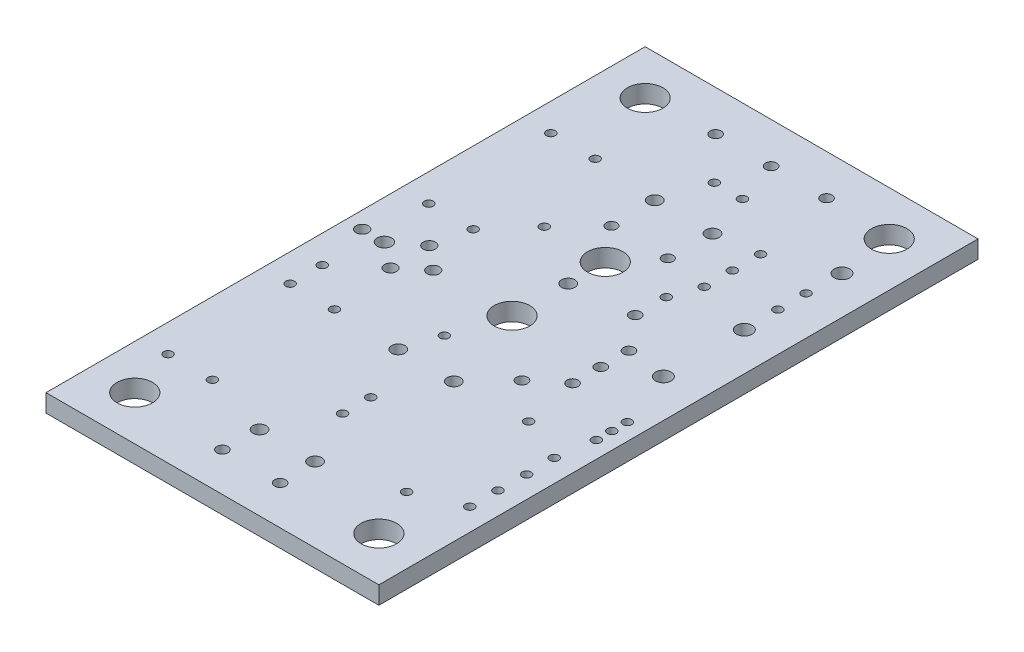
from build123d import *

# Parameters (mm, degrees)
ESQUISSE2_W      = 30
ESQUISSE2_H      = 54
ESQUISSE2_R      = 0.59944
ESQUISSE2_R_2    = 1.6002
ESQUISSE2_R_3    = 0.50038
ESQUISSE2_R_4    = 0.4826
ESQUISSE2_R_5    = 0.39878
ESQUISSE2_R_6    = 0.55118
ESQUISSE2_R_7    = 0.65024
ESQUISSE2_R_8    = 0.70104
ESQUISSE2_R_9    = 0.4
EXTRUSION1_DEPTH = 1.6


with BuildPart() as part:
    # Esquisse2 → Extrusion1 (new body)
    with BuildSketch(Plane(origin=(0, 0, 0), x_dir=(1, 0, 0), z_dir=(0, 1, 0))):
        with Locations((15, 27)):
            Rectangle(ESQUISSE2_W, ESQUISSE2_H)
        with Locations(Location((17.62252, 42.44594, 0), (0, 0, 270))):  # turned: the seam where the file's is
            Circle(ESQUISSE2_R, mode=Mode.SUBTRACT)
        with Locations(Location((12.4206, 42.44594, 0), (0, 0, 270))):  # turned: the seam where the file's is
            Circle(ESQUISSE2_R, mode=Mode.SUBTRACT)
        with Locations(Location((15.02156, 32.04464, 0), (0, 0, 270))):  # turned: the seam where the file's is
            Circle(ESQUISSE2_R, mode=Mode.SUBTRACT)
        with Locations(Location((15.00378, 35.40252, 0), (0, 0, 270))):  # turned: the seam where the file's is
            Circle(ESQUISSE2_R_2, mode=Mode.SUBTRACT)
        with Locations(Location((17.59966, 3.50012, 0), (0, 0, 270))):  # turned: the seam where the file's is
            Circle(ESQUISSE2_R_3, mode=Mode.SUBTRACT)
        with Locations(Location((12.40028, 3.50012, 0), (0, 0, 270))):  # turned: the seam where the file's is
            Circle(ESQUISSE2_R_3, mode=Mode.SUBTRACT)
        with Locations(Location((15.00124, 50.35042, 0), (0, 0, 270))):  # turned: the seam where the file's is
            Circle(ESQUISSE2_R_3, mode=Mode.SUBTRACT)
        with Locations(Location((19.99996, 50.35042, 0), (0, 0, 270))):  # turned: the seam where the file's is
            Circle(ESQUISSE2_R_3, mode=Mode.SUBTRACT)
        with Locations(Location((9.99998, 50.35042, 0), (0, 0, 270))):  # turned: the seam where the file's is
            Circle(ESQUISSE2_R_3, mode=Mode.SUBTRACT)
        with Locations(Location((12.49934, 19.25066, 0), (0, 0, 270))):  # turned: the seam where the file's is
            Circle(ESQUISSE2_R, mode=Mode.SUBTRACT)
        with Locations(Location((12.49934, 6.74878, 0), (0, 0, 270))):  # turned: the seam where the file's is
            Circle(ESQUISSE2_R, mode=Mode.SUBTRACT)
        with Locations(Location((17.5006, 19.25066, 0), (0, 0, 270))):  # turned: the seam where the file's is
            Circle(ESQUISSE2_R, mode=Mode.SUBTRACT)
        with Locations(Location((17.5006, 6.74878, 0), (0, 0, 270))):  # turned: the seam where the file's is
            Circle(ESQUISSE2_R, mode=Mode.SUBTRACT)
        with Locations(Location((20.50034, 22.40026, 0), (0, 0, 270))):  # turned: the seam where the file's is
            Circle(ESQUISSE2_R_3, mode=Mode.SUBTRACT)
        with Locations(Location((20.50034, 32.6009, 0), (0, 0, 270))):  # turned: the seam where the file's is
            Circle(ESQUISSE2_R_3, mode=Mode.SUBTRACT)
        with Locations(Location((12.46124, 38.49878, 0), (0, 0, 270))):  # turned: the seam where the file's is
            Circle(ESQUISSE2_R_4, mode=Mode.SUBTRACT)
        with Locations(Location((17.54124, 38.49878, 0), (0, 0, 270))):  # turned: the seam where the file's is
            Circle(ESQUISSE2_R_4, mode=Mode.SUBTRACT)
        with Locations(Location((16.27124, 46.49978, 0), (0, 0, 270))):  # turned: the seam where the file's is
            Circle(ESQUISSE2_R_5, mode=Mode.SUBTRACT)
        with Locations(Location((13.73124, 46.49978, 0), (0, 0, 270))):  # turned: the seam where the file's is
            Circle(ESQUISSE2_R_5, mode=Mode.SUBTRACT)
        with Locations(Location((15.00124, 11.72972, 0), (0, 0, 270))):  # turned: the seam where the file's is
            Circle(ESQUISSE2_R_5, mode=Mode.SUBTRACT)
        with Locations(Location((15.00124, 14.26972, 0), (0, 0, 270))):  # turned: the seam where the file's is
            Circle(ESQUISSE2_R_5, mode=Mode.SUBTRACT)
        with Locations(Location((1.4986, 27.0002, 0), (0, 0, 270))):  # turned: the seam where the file's is
            Circle(ESQUISSE2_R_6, mode=Mode.SUBTRACT)
        with Locations(Location((7.8994, 27.0002, 0), (0, 0, 270))):  # turned: the seam where the file's is
            Circle(ESQUISSE2_R_6, mode=Mode.SUBTRACT)
        with Locations(Location((5.79882, 25.25014, 0), (0, 0, 270))):  # turned: the seam where the file's is
            Circle(ESQUISSE2_R_6, mode=Mode.SUBTRACT)
        with Locations(Location((5.79882, 28.75026, 0), (0, 0, 270))):  # turned: the seam where the file's is
            Circle(ESQUISSE2_R_6, mode=Mode.SUBTRACT)
        with Locations(Location((3.50012, 27.0002, 0), (0, 0, 270))):  # turned: the seam where the file's is
            Circle(ESQUISSE2_R_7, mode=Mode.SUBTRACT)
        with Locations(Location((4.0005, 49.9999, 0), (0, 0, 270))):  # turned: the seam where the file's is
            Circle(ESQUISSE2_R_2, mode=Mode.SUBTRACT)
        with Locations(Location((25.99944, 49.9999, 0), (0, 0, 270))):  # turned: the seam where the file's is
            Circle(ESQUISSE2_R_2, mode=Mode.SUBTRACT)
        with Locations(Location((4.0005, 4.0005, 0), (0, 0, 270))):  # turned: the seam where the file's is
            Circle(ESQUISSE2_R_2, mode=Mode.SUBTRACT)
        with Locations(Location((15.00124, 27.0002, 0), (0, 0, 270))):  # turned: the seam where the file's is
            Circle(ESQUISSE2_R_2, mode=Mode.SUBTRACT)
        with Locations(Location((25.99944, 4.0005, 0), (0, 0, 270))):  # turned: the seam where the file's is
            Circle(ESQUISSE2_R_2, mode=Mode.SUBTRACT)
        with Locations(Location((22.9997, 24.4602, 0), (0, 0, 270))):  # turned: the seam where the file's is
            Circle(ESQUISSE2_R_3, mode=Mode.SUBTRACT)
        with Locations(Location((22.9997, 27.0002, 0), (0, 0, 270))):  # turned: the seam where the file's is
            Circle(ESQUISSE2_R_3, mode=Mode.SUBTRACT)
        with Locations(Location((22.9997, 29.5402, 0), (0, 0, 270))):  # turned: the seam where the file's is
            Circle(ESQUISSE2_R_3, mode=Mode.SUBTRACT)
        with Locations(Location((28.04922, 15.27048, 0), (0, 0, 270))):  # turned: the seam where the file's is
            Circle(ESQUISSE2_R_5, mode=Mode.SUBTRACT)
        with Locations(Location((28.00096, 12.73048, 0), (0, 0, 270))):  # turned: the seam where the file's is
            Circle(ESQUISSE2_R_5, mode=Mode.SUBTRACT)
        with Locations(Location((28.00096, 10.19048, 0), (0, 0, 270))):  # turned: the seam where the file's is
            Circle(ESQUISSE2_R_5, mode=Mode.SUBTRACT)
        with Locations(Location((28.00096, 17.81048, 0), (0, 0, 270))):  # turned: the seam where the file's is
            Circle(ESQUISSE2_R_5, mode=Mode.SUBTRACT)
        with Locations(Location((26.49982, 41.9989, 0), (0, 0, 270))):  # turned: the seam where the file's is
            Circle(ESQUISSE2_R_5, mode=Mode.SUBTRACT)
        with Locations(Location((26.49982, 39.4589, 0), (0, 0, 270))):  # turned: the seam where the file's is
            Circle(ESQUISSE2_R_5, mode=Mode.SUBTRACT)
        with Locations(Location((26.56078, 45.17898, 0), (0, 0, 270))):  # turned: the seam where the file's is
            Circle(ESQUISSE2_R_8, mode=Mode.SUBTRACT)
        with Locations(Location((26.56078, 36.38042, 0), (0, 0, 270))):  # turned: the seam where the file's is
            Circle(ESQUISSE2_R_8, mode=Mode.SUBTRACT)
        with Locations(Location((26.56078, 29.08046, 0), (0, 0, 270))):  # turned: the seam where the file's is
            Circle(ESQUISSE2_R_8, mode=Mode.SUBTRACT)
        with Locations(Location((24.00046, 8.49884, 0), (0, 0, 270))):  # turned: the seam where the file's is
            Circle(ESQUISSE2_R_5, mode=Mode.SUBTRACT)
        with Locations(Location((24.00046, 19.49958, 0), (0, 0, 270))):  # turned: the seam where the file's is
            Circle(ESQUISSE2_R_5, mode=Mode.SUBTRACT)
        with Locations(Location((6.49986, 42.99966, 0), (0, 0, 270))):  # turned: the seam where the file's is
            Circle(ESQUISSE2_R_5, mode=Mode.SUBTRACT)
        with Locations(Location((6.49986, 31.99892, 0), (0, 0, 270))):  # turned: the seam where the file's is
            Circle(ESQUISSE2_R_5, mode=Mode.SUBTRACT)
        with Locations(Location((2.49936, 42.99966, 0), (0, 0, 270))):  # turned: the seam where the file's is
            Circle(ESQUISSE2_R_5, mode=Mode.SUBTRACT)
        with Locations(Location((2.49936, 31.99892, 0), (0, 0, 270))):  # turned: the seam where the file's is
            Circle(ESQUISSE2_R_5, mode=Mode.SUBTRACT)
        with Locations(Location((6.49986, 8.49884, 0), (0, 0, 270))):  # turned: the seam where the file's is
            Circle(ESQUISSE2_R_5, mode=Mode.SUBTRACT)
        with Locations(Location((6.49986, 19.49958, 0), (0, 0, 270))):  # turned: the seam where the file's is
            Circle(ESQUISSE2_R_5, mode=Mode.SUBTRACT)
        with Locations(Location((2.49936, 8.49884, 0), (0, 0, 270))):  # turned: the seam where the file's is
            Circle(ESQUISSE2_R_5, mode=Mode.SUBTRACT)
        with Locations(Location((2.49936, 19.49958, 0), (0, 0, 270))):  # turned: the seam where the file's is
            Circle(ESQUISSE2_R_5, mode=Mode.SUBTRACT)
        with Locations(Location((2.49936, 22.40026, 0), (0, 0, 270))):  # turned: the seam where the file's is
            Circle(ESQUISSE2_R_5, mode=Mode.SUBTRACT)
        with Locations(Location((13.5001, 22.40026, 0), (0, 0, 270))):  # turned: the seam where the file's is
            Circle(ESQUISSE2_R_5, mode=Mode.SUBTRACT)
        with Locations(Location((28.4988, 21.09978, 0), (0, 0, 270))):  # turned: the seam where the file's is
            Circle(ESQUISSE2_R_5, mode=Mode.SUBTRACT)
        with Locations(Location((28.4988, 22.49932, 0), (0, 0, 270))):  # turned: the seam where the file's is
            Circle(ESQUISSE2_R_5, mode=Mode.SUBTRACT)
        with Locations(Location((28.4988, 23.89886, 0), (0, 0, 270))):  # turned: the seam where the file's is
            Circle(ESQUISSE2_R_5, mode=Mode.SUBTRACT)
        with Locations(Location((21.4, 43, 0), (0, 0, 270))):  # turned: the seam where the file's is
            Circle(ESQUISSE2_R_9, mode=Mode.SUBTRACT)
        with Locations(Location((21.4, 40.46, 0), (0, 0, 270))):  # turned: the seam where the file's is
            Circle(ESQUISSE2_R_9, mode=Mode.SUBTRACT)
        with Locations(Location((21.4, 37.92, 0), (0, 0, 270))):  # turned: the seam where the file's is
            Circle(ESQUISSE2_R_9, mode=Mode.SUBTRACT)
        with Locations(Location((20.5, 35.40252, 0), (0, 0, 270))):  # turned: the seam where the file's is
            Circle(ESQUISSE2_R_9, mode=Mode.SUBTRACT)
        with Locations(Location((9.5, 35.40252, 0), (0, 0, 270))):  # turned: the seam where the file's is
            Circle(ESQUISSE2_R_9, mode=Mode.SUBTRACT)
    extrude(amount=EXTRUSION1_DEPTH)


solid = part.part
